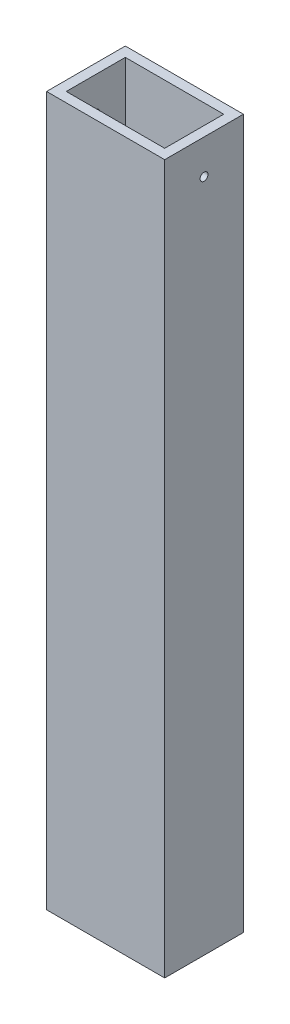
from build123d import *

# Parameters (mm, degrees)
SKETCH1_W               = 76.2
SKETCH1_H               = 50.8
SKETCH1_W_2             = 63.5
SKETCH1_H_2             = 38.1
BOSS_EXTRUDE1_DEPTH     = 457.2
F_1_4_20_TAPPED_HOLE1_D = 5.1054


with BuildPart() as part:
    # Sketch1 → Boss-Extrude1 (new body)
    with BuildSketch(Plane(origin=(0, 0, 0), x_dir=(1, 0, 0), z_dir=(0, 1, 0))):
        Rectangle(SKETCH1_W, SKETCH1_H)
        Rectangle(SKETCH1_W_2, SKETCH1_H_2, mode=Mode.SUBTRACT)
    extrude(amount=BOSS_EXTRUDE1_DEPTH)

    # 1/4-20 Tapped Hole1 (through all)
    with Locations(Plane.ZY.offset(38.1)):
        with Locations((0, 434.975)):
            Hole(F_1_4_20_TAPPED_HOLE1_D / 2)


solid = part.part
